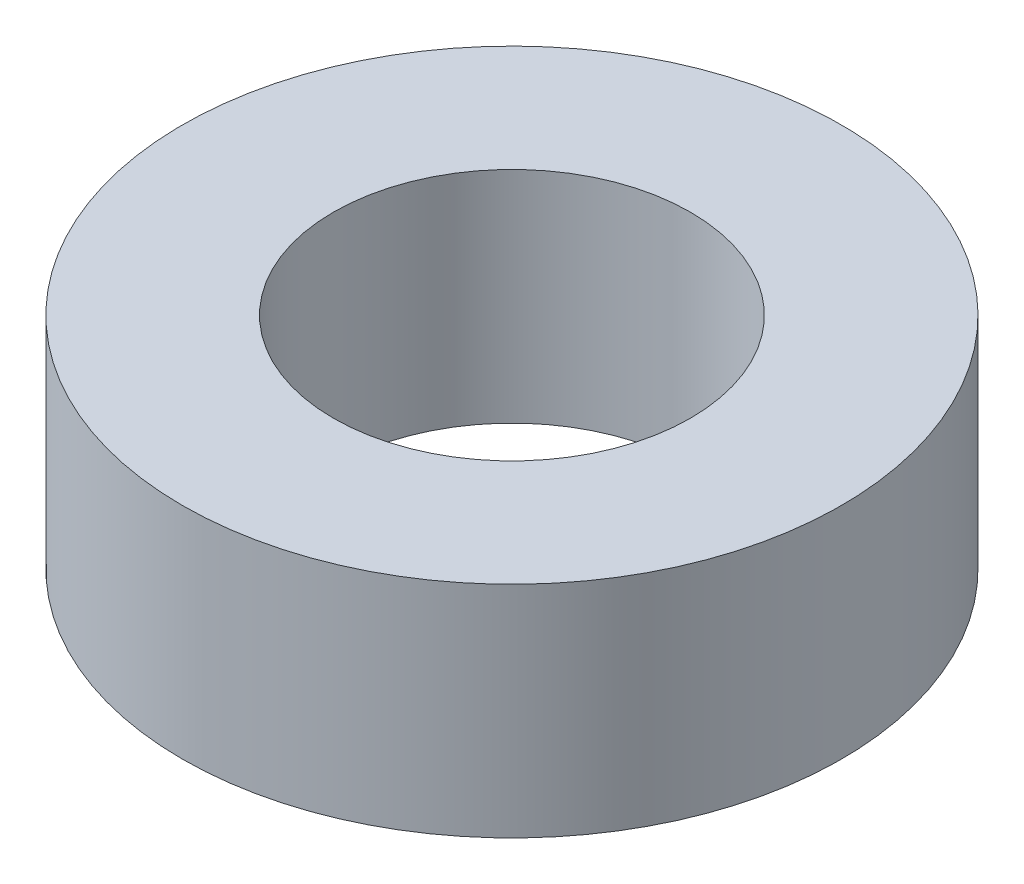
from build123d import *

# Parameters (mm, degrees)
SKETCH1_R           = 6
SKETCH1_R_2         = 3.25
BOSS_EXTRUDE1_DEPTH = 4


with BuildPart() as part:
    # Sketch1 → Boss-Extrude1 (new body)
    with BuildSketch(Plane(origin=(0, 0, 0), x_dir=(1, 0, 0), z_dir=(0, 1, 0))):
        Circle(SKETCH1_R)
        Circle(SKETCH1_R_2, mode=Mode.SUBTRACT)
    extrude(amount=BOSS_EXTRUDE1_DEPTH)


solid = part.part
